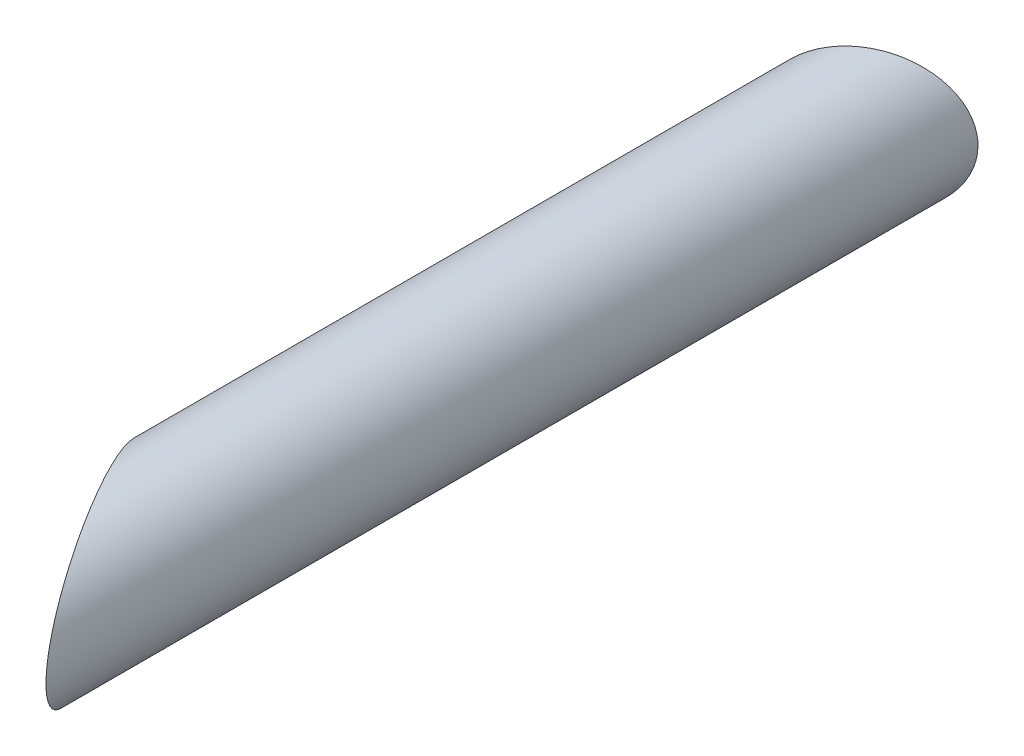
from build123d import *

# Parameters (mm, degrees)
SKETCH1_R                 = 7.5
BOSS_EXTRUDE1_DEPTH       = 100
CUT_EXTRUDE1_DEPTH        = 8.5
CUT_EXTRUDE1_DEPTH_BACK   = 8.5
M5X0_8_TAPPED_HOLE2_D     = 4.2
M5X0_8_TAPPED_HOLE2_DEPTH = 10
M5X0_8_TAPPED_HOLE2_TIP   = 1.2618073
M5X0_8_TAPPED_HOLE3_D     = 4.2
M5X0_8_TAPPED_HOLE3_DEPTH = 7
M5X0_8_TAPPED_HOLE3_TIP   = 1.2618073


with BuildPart() as part:
    # Sketch1 → Boss-Extrude1 (new body)
    with BuildSketch(Plane.XY):
        Circle(SKETCH1_R)
    extrude(amount=BOSS_EXTRUDE1_DEPTH)

    # Sketch5 → Cut-Extrude1 (cut, two sides)
    with BuildSketch(Plane(origin=(0, 0, 0), x_dir=(1, 0, 0), z_dir=(0, 1, 0))) as cut_extrude1_sk:
        Polygon((7.5, 0), (-7.5, -8.660254038), (-7.5, 0), align=None)
        Polygon((7.5, -100), (-4.922116598, -78.484262915), (-7.5, -74.019237886), (-7.5, -100), align=None)
    extrude(amount=CUT_EXTRUDE1_DEPTH, mode=Mode.SUBTRACT)
    extrude(cut_extrude1_sk.sketch, amount=-CUT_EXTRUDE1_DEPTH_BACK, mode=Mode.SUBTRACT)

    # M5x0.8 Tapped Hole2
    with Locations(Plane(origin=(1.875, 0, 3.247595264), x_dir=(-0.866025404, 0, 0.5), z_dir=(-0.5, 0, -0.866025404))):
        with Locations((4.825317547, 0)):
            Hole(M5X0_8_TAPPED_HOLE2_D / 2, depth=M5X0_8_TAPPED_HOLE2_DEPTH)
            with Locations((0, 0, -(M5X0_8_TAPPED_HOLE2_DEPTH + M5X0_8_TAPPED_HOLE2_TIP / 2))):  # 118° drill point
                Cone(0, M5X0_8_TAPPED_HOLE2_D / 2, M5X0_8_TAPPED_HOLE2_TIP, mode=Mode.SUBTRACT)

    # M5x0.8 Tapped Hole3
    with Locations(Plane(origin=(-37.676270189, 0, 21.752404736), x_dir=(0.5, 0, 0.866025404), z_dir=(-0.866025404, 0, 0.5))):
        with Locations((68.352540378, 0)):
            Hole(M5X0_8_TAPPED_HOLE3_D / 2, depth=M5X0_8_TAPPED_HOLE3_DEPTH)
            with Locations((0, 0, -(M5X0_8_TAPPED_HOLE3_DEPTH + M5X0_8_TAPPED_HOLE3_TIP / 2))):  # 118° drill point
                Cone(0, M5X0_8_TAPPED_HOLE3_D / 2, M5X0_8_TAPPED_HOLE3_TIP, mode=Mode.SUBTRACT)


solid = part.part
